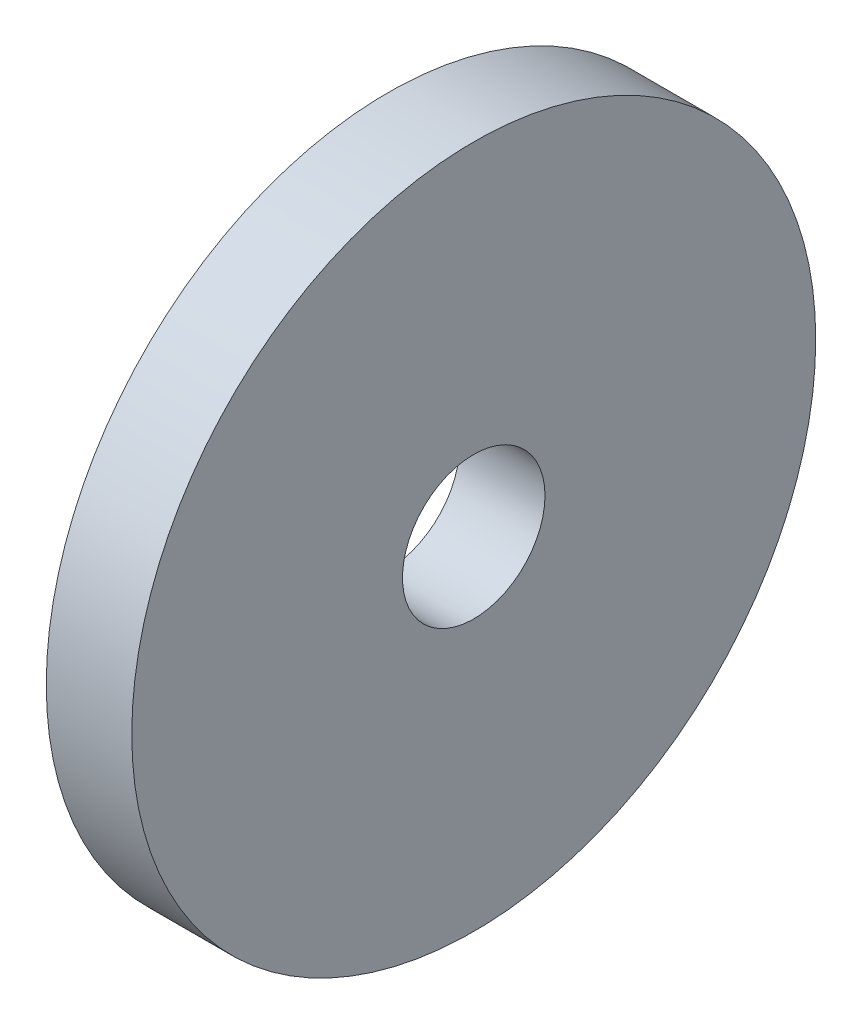
from build123d import *

# Parameters (mm, degrees)
SKETCH1_R               = 12
GEAR_BODY_EXTRUDE_DEPTH = 3
SKETCH2_R               = 2.5
AXLE_HOLE_DEPTH         = 3


with BuildPart() as part:
    # Sketch1 → gear_body_extrude (new body)
    with BuildSketch(Plane(origin=(0, 0, 0), x_dir=(0, 0, -1), z_dir=(1, 0, 0))):
        Circle(SKETCH1_R)
    extrude(amount=GEAR_BODY_EXTRUDE_DEPTH)

    # Sketch2 → axle_hole (cut)
    with BuildSketch(Plane(origin=(3, 0, 0), x_dir=(0, 0, -1), z_dir=(1, 0, 0))):
        Circle(SKETCH2_R)
    extrude(amount=-AXLE_HOLE_DEPTH, mode=Mode.SUBTRACT)


solid = part.part
